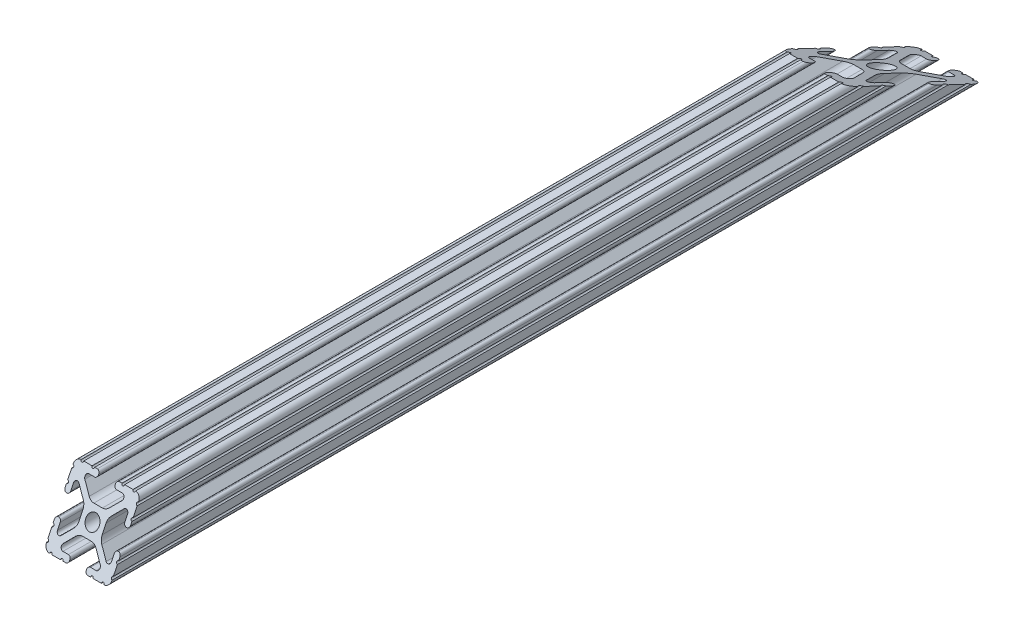
from build123d import *

# Parameters (mm, degrees)
SKETCH1_R               = 2.6035
BOSS_EXTRUDE1_DEPTH     = 185
CUT_EXTRUDE4_DEPTH      = 1
CUT_EXTRUDE4_DEPTH_BACK = 26.4


with BuildPart() as part:
    # Sketch1 → Boss-Extrude1 (new body, symmetric)
    with BuildSketch(Plane.XY):
        with BuildLine():
            Line((-7.179650497, -8.645192506), (-3.952270251, -5.423690499))
            ThreePointArc((-3.952270251, -5.423690499), (-2.922936451, -4.736929036), (-1.709253557, -4.4958))
            Line((-1.709253557, -4.4958), (1.709253557, -4.4958))
            ThreePointArc((1.709253557, -4.4958), (2.922936451, -4.736929036), (3.952270251, -5.423690499))
            Line((3.952270251, -5.423690499), (7.179650497, -8.645192506))
            ThreePointArc((7.179650497, -8.645192506), (7.41473083, -9.822813117), (6.416408329, -10.4902))
            Line((6.416408329, -10.4902), (4.287512407, -10.4902))
            ThreePointArc((4.287512407, -10.4902), (3.54574862, -10.79744862), (3.2385, -11.539212407))
            Line((3.2385, -11.539212407), (3.2385, -11.650987593))
            ThreePointArc((3.2385, -11.650987593), (3.54574862, -12.39275138), (4.287512407, -12.7))
            Line((4.287512407, -12.7), (5.317126718, -12.7))
            ThreePointArc((5.317126718, -12.7), (5.825126718, -12.192), (6.333126718, -12.7))
            Line((6.333126718, -12.7), (9.550443118, -12.7))
            ThreePointArc((9.550443118, -12.7), (10.058366869, -12.192000006), (10.566443095, -12.699847501))
            ThreePointArc((10.566443095, -12.699847501), (12.082537762, -12.08250727), (12.699846982, -10.566399977))
            ThreePointArc((12.699846982, -10.566399977), (12.192000006, -10.058323491), (12.7, -9.5504))
            Line((12.7, -9.5504), (12.7, -6.3330836))
            ThreePointArc((12.7, -6.3330836), (12.192, -5.8250836), (12.7, -5.3170836))
            Line((12.7, -5.3170836), (12.7, -4.287469289))
            ThreePointArc((12.7, -4.287469289), (12.39275138, -3.545705502), (11.650987593, -3.238456882))
            Line((11.650987593, -3.238456882), (11.539212407, -3.238456882))
            ThreePointArc((11.539212407, -3.238456882), (10.79744862, -3.545705502), (10.4902, -4.287469289))
            Line((10.4902, -4.287469289), (10.4902, -6.402089023))
            ThreePointArc((10.4902, -6.402089023), (9.856505071, -7.351067942), (8.737131347, -7.129408934))
            Line((8.737131347, -7.129408934), (5.441005833, -3.840816462))
            ThreePointArc((5.441005833, -3.840816462), (4.750877967, -2.809883091), (4.5085, -1.593185507))
            Line((4.5085, -1.593185507), (4.5085, 1.593185507))
            ThreePointArc((4.5085, 1.593185507), (4.750877967, 2.809883091), (5.441005833, 3.840816462))
            Line((5.441005833, 3.840816462), (8.737131347, 7.129408934))
            ThreePointArc((8.737131347, 7.129408934), (9.856505071, 7.351067942), (10.4902, 6.402089023))
            Line((10.4902, 6.402089023), (10.4902, 4.287469289))
            ThreePointArc((10.4902, 4.287469289), (10.79744862, 3.545705502), (11.539212407, 3.238456882))
            Line((11.539212407, 3.238456882), (11.650987593, 3.238456882))
            ThreePointArc((11.650987593, 3.238456882), (12.39275138, 3.545705502), (12.7, 4.287469289))
            Line((12.7, 4.287469289), (12.7, 5.3170836))
            ThreePointArc((12.7, 5.3170836), (12.192, 5.8250836), (12.7, 6.3330836))
            Line((12.7, 6.3330836), (12.7, 9.5504))
            ThreePointArc((12.7, 9.5504), (12.192000006, 10.058323491), (12.699846982, 10.566399977))
            ThreePointArc((12.699846982, 10.566399977), (12.082537762, 12.08250727), (10.566443095, 12.699847501))
            ThreePointArc((10.566443095, 12.699847501), (10.058366869, 12.192000006), (9.550443118, 12.7))
            Line((9.550443118, 12.7), (6.333126718, 12.7))
            ThreePointArc((6.333126718, 12.7), (5.825126718, 12.192), (5.317126718, 12.7))
            Line((5.317126718, 12.7), (4.287512407, 12.7))
            ThreePointArc((4.287512407, 12.7), (3.54574862, 12.39275138), (3.2385, 11.650987593))
            Line((3.2385, 11.650987593), (3.2385, 11.539212407))
            ThreePointArc((3.2385, 11.539212407), (3.54574862, 10.79744862), (4.287512407, 10.4902))
            Line((4.287512407, 10.4902), (6.476788598, 10.4902))
            ThreePointArc((6.476788598, 10.4902), (7.432222385, 9.85140422), (7.207036008, 8.724370562))
            Line((7.207036008, 8.724370562), (3.898272566, 5.423169045))
            ThreePointArc((3.898272566, 5.423169045), (2.869120213, 4.736787962), (1.655778399, 4.4958))
            Line((1.655778399, 4.4958), (-1.655778399, 4.4958))
            ThreePointArc((-1.655778399, 4.4958), (-2.869120213, 4.736787962), (-3.898272566, 5.423169045))
            Line((-3.898272566, 5.423169045), (-7.207036008, 8.724370562))
            ThreePointArc((-7.207036008, 8.724370562), (-7.432222385, 9.85140422), (-6.476788598, 10.4902))
            Line((-6.476788598, 10.4902), (-4.287512407, 10.4902))
            ThreePointArc((-4.287512407, 10.4902), (-3.54574862, 10.79744862), (-3.2385, 11.539212407))
            Line((-3.2385, 11.539212407), (-3.2385, 11.650987593))
            ThreePointArc((-3.2385, 11.650987593), (-3.54574862, 12.39275138), (-4.287512407, 12.7))
            Line((-4.287512407, 12.7), (-5.317126718, 12.7))
            ThreePointArc((-5.317126718, 12.7), (-5.825126718, 12.192), (-6.333126718, 12.7))
            Line((-6.333126718, 12.7), (-9.550443118, 12.7))
            ThreePointArc((-9.550443118, 12.7), (-10.058366869, 12.192000006), (-10.566443095, 12.699847501))
            ThreePointArc((-10.566443095, 12.699847501), (-12.082537762, 12.08250727), (-12.699846982, 10.566399977))
            ThreePointArc((-12.699846982, 10.566399977), (-12.192000006, 10.058323491), (-12.7, 9.5504))
            Line((-12.7, 9.5504), (-12.7, 6.3330836))
            ThreePointArc((-12.7, 6.3330836), (-12.192, 5.8250836), (-12.7, 5.3170836))
            Line((-12.7, 5.3170836), (-12.7, 4.287469289))
            ThreePointArc((-12.7, 4.287469289), (-12.39275138, 3.545705502), (-11.650987593, 3.238456882))
            Line((-11.650987593, 3.238456882), (-11.539212407, 3.238456882))
            ThreePointArc((-11.539212407, 3.238456882), (-10.79744862, 3.545705502), (-10.4902, 4.287469289))
            Line((-10.4902, 4.287469289), (-10.4902, 6.402089023))
            ThreePointArc((-10.4902, 6.402089023), (-9.856505071, 7.351067942), (-8.737131347, 7.129408934))
            Line((-8.737131347, 7.129408934), (-5.441005833, 3.840816462))
            ThreePointArc((-5.441005833, 3.840816462), (-4.750877967, 2.809883091), (-4.5085, 1.593185507))
            Line((-4.5085, 1.593185507), (-4.5085, -1.593185507))
            ThreePointArc((-4.5085, -1.593185507), (-4.750877967, -2.809883091), (-5.441005833, -3.840816462))
            Line((-5.441005833, -3.840816462), (-8.737131347, -7.129408934))
            ThreePointArc((-8.737131347, -7.129408934), (-9.856505071, -7.351067942), (-10.4902, -6.402089023))
            Line((-10.4902, -6.402089023), (-10.4902, -4.287469289))
            ThreePointArc((-10.4902, -4.287469289), (-10.79744862, -3.545705502), (-11.539212407, -3.238456882))
            Line((-11.539212407, -3.238456882), (-11.650987593, -3.238456882))
            ThreePointArc((-11.650987593, -3.238456882), (-12.39275138, -3.545705502), (-12.7, -4.287469289))
            Line((-12.7, -4.287469289), (-12.7, -5.3170836))
            ThreePointArc((-12.7, -5.3170836), (-12.192, -5.8250836), (-12.7, -6.3330836))
            Line((-12.7, -6.3330836), (-12.7, -9.5504))
            ThreePointArc((-12.7, -9.5504), (-12.192000006, -10.058323491), (-12.699846982, -10.566399977))
            ThreePointArc((-12.699846982, -10.566399977), (-12.082537762, -12.08250727), (-10.566443095, -12.699847501))
            ThreePointArc((-10.566443095, -12.699847501), (-10.058366869, -12.192000006), (-9.550443118, -12.7))
            Line((-9.550443118, -12.7), (-6.333126718, -12.7))
            ThreePointArc((-6.333126718, -12.7), (-5.825126718, -12.192), (-5.317126718, -12.7))
            Line((-5.317126718, -12.7), (-4.287512407, -12.7))
            ThreePointArc((-4.287512407, -12.7), (-3.54574862, -12.39275138), (-3.2385, -11.650987593))
            Line((-3.2385, -11.650987593), (-3.2385, -11.539212407))
            ThreePointArc((-3.2385, -11.539212407), (-3.54574862, -10.79744862), (-4.287512407, -10.4902))
            Line((-4.287512407, -10.4902), (-6.416408329, -10.4902))
            ThreePointArc((-6.416408329, -10.4902), (-7.41473083, -9.822813117), (-7.179650497, -8.645192506))
        make_face()
        Circle(SKETCH1_R, mode=Mode.SUBTRACT)
    extrude(amount=BOSS_EXTRUDE1_DEPTH, both=True)

    # Sketch2 → Cut-Extrude4 (cut, two sides)
    with BuildSketch(Plane(origin=(12.7, 0, 0), x_dir=(0, 0, -1), z_dir=(1, 0, 0))) as cut_extrude4_sk:
        Polygon((-164.46464742, 25.628344266), (-188.10813452, -23.262665694), (-213.259000162, -11.09981269), (-189.615513062, 37.79119727), align=None)
        Polygon((76.313561137, 25.628344266), (208.869262725, -38.475036358), (239.869388394, 25.628344266), (107.313686806, 89.73172489), align=None)
    extrude(amount=CUT_EXTRUDE4_DEPTH, mode=Mode.SUBTRACT)
    extrude(cut_extrude4_sk.sketch, amount=-CUT_EXTRUDE4_DEPTH_BACK, mode=Mode.SUBTRACT)


solid = part.part
